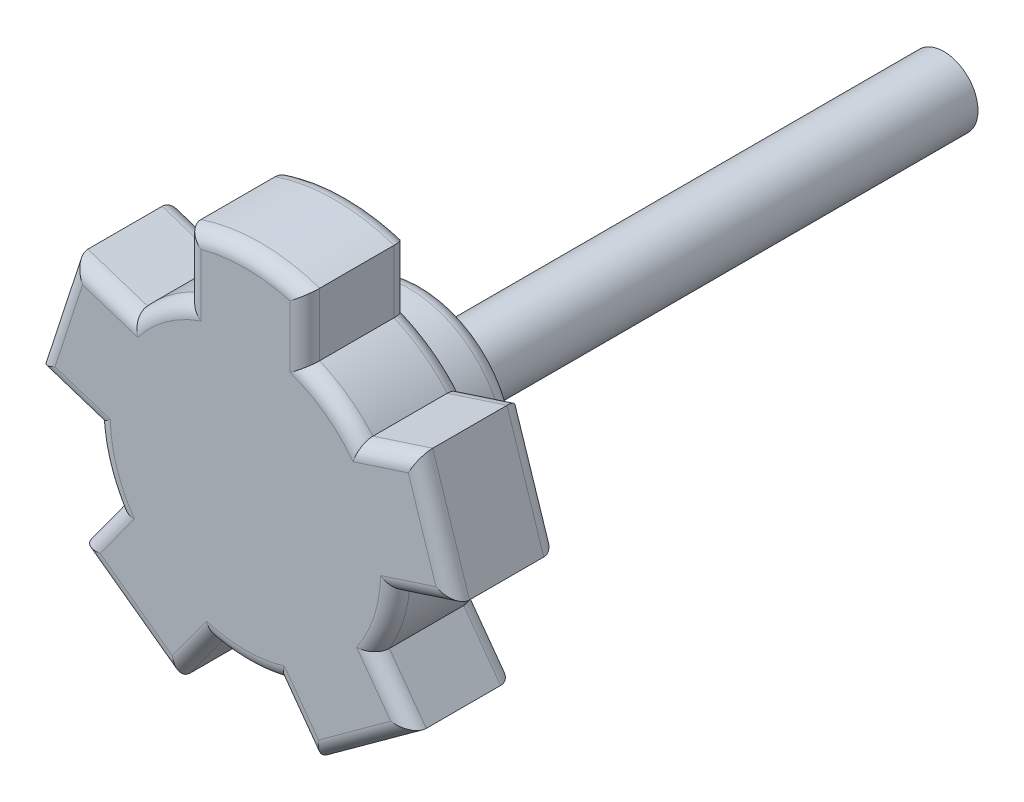
from build123d import *

# Parameters (mm, degrees)
SKETCH1_R      = 2.921
EXTRUDE1_DEPTH = 44.45
SKETCH2_R      = 8.255
EXTRUDE2_DEPTH = 6.35
SKETCH3_R      = 12.827
EXTRUDE3_DEPTH = 8.89
EXTRUDE6_DEPTH = 8.89
EXTRUDE7_DEPTH = 8.89
FILLET1_R      = 1.27


with BuildPart() as part:
    # Sketch1 → Extrude1 (new body)
    with BuildSketch(Plane.XY):
        Circle(SKETCH1_R)
    extrude(amount=EXTRUDE1_DEPTH)

    # Sketch2 → Extrude2 (add)
    with BuildSketch(Plane.XY.offset(44.45)):
        Circle(SKETCH2_R)
    extrude(amount=EXTRUDE2_DEPTH)

    # Sketch3 → Extrude3 (add)
    with BuildSketch(Plane.XY.offset(50.8)):
        Circle(SKETCH3_R)
    extrude(amount=EXTRUDE3_DEPTH)

    # Sketch4 → Extrude6 (add)
    with BuildSketch(Plane.XY.offset(59.69)):
        with BuildLine():
            Line((9.631908705, 8.47102495), (14.73605764, 10.129463471))
            Line((14.73605764, 10.129463471), (17.875670303, 0.466729266))
            Line((17.875670303, 0.466729266), (12.771521368, -1.191709256))
            ThreePointArc((12.771521368, -1.191709256), (12.199201935, 3.963760987), (9.631908705, 8.47102495))
        make_face()
        with BuildLine():
            Line((-5.08, 11.778180207), (-5.08, 17.145))
            Line((-5.08, 17.145), (5.08, 17.145))
            Line((5.08, 17.145), (5.08, 11.778180207))
            ThreePointArc((5.08, 11.778180207), (0, 12.827), (-5.08, 11.778180207))
        make_face()
        with BuildLine():
            Line((11.032846956, -6.542798869), (14.187384482, -10.884647287))
            Line((14.187384482, -10.884647287), (5.967771819, -16.85654545))
            Line((5.967771819, -16.85654545), (2.813234293, -12.514697032))
            ThreePointArc((2.813234293, -12.514697032), (7.539521431, -10.377260987), (11.032846956, -6.542798869))
        make_face()
        with BuildLine():
            Line((-2.813234293, -12.514697032), (-5.967771819, -16.85654545))
            Line((-5.967771819, -16.85654545), (-14.187384482, -10.884647287))
            Line((-14.187384482, -10.884647287), (-11.032846956, -6.542798869))
            ThreePointArc((-11.032846956, -6.542798869), (-7.539521431, -10.377260987), (-2.813234293, -12.514697032))
        make_face()
        with BuildLine():
            Line((-12.771521368, -1.191709256), (-17.875670303, 0.466729266))
            Line((-17.875670303, 0.466729266), (-14.73605764, 10.129463471))
            Line((-14.73605764, 10.129463471), (-9.631908705, 8.47102495))
            ThreePointArc((-9.631908705, 8.47102495), (-12.199201935, 3.963760987), (-12.771521368, -1.191709256))
        make_face()
    extrude(amount=-EXTRUDE6_DEPTH)

    # Sketch7 → Extrude7 (add)
    with BuildSketch(Plane.XY.offset(59.69)):
        with BuildLine():
            Line((5.08, 17.145), (-5.08, 17.145))
            ThreePointArc((-5.08, 17.145), (0, 17.989354528), (5.08, 17.145))
        make_face()
    extrude(amount=-EXTRUDE7_DEPTH)

    # Fillet1
    fillet1_edges = [part.edges().sort_by_distance(p)[0] for p in [
        (-7.539521431, 10.377260987, 59.69),
        (-7.539521431, 10.377260987, 50.8),
        (5.08, 14.461590104, 59.69),
        (-5.08, 14.461590104, 59.69),
        (5.08, 14.461590104, 50.8),
        (-5.08, 14.461590104, 50.8),
        (7.539521431, 10.377260987, 59.69),
        (7.539521431, 10.377260987, 50.8),
        (15.323595836, -0.362489995, 59.69),
        (16.305863972, 5.298096369, 59.69),
        (12.183983173, 9.300244211, 59.69),
        (15.323595836, -0.362489995, 50.8),
        (12.183983173, 9.300244211, 50.8),
        (16.305863972, 5.298096369, 50.8),
        (12.199201935, -3.963760987, 59.69),
        (12.199201935, -3.963760987, 50.8),
        (4.390503056, -14.685621241, 59.69),
        (10.077578151, -13.870596369, 59.69),
        (12.610115719, -8.713723078, 59.69),
        (4.390503056, -14.685621241, 50.8),
        (12.610115719, -8.713723078, 50.8),
        (10.077578151, -13.870596369, 50.8),
        (0, -12.827, 59.69),
        (0, -12.827, 50.8),
        (-12.610115719, -8.713723078, 59.69),
        (-10.077578151, -13.870596369, 59.69),
        (-4.390503056, -14.685621241, 59.69),
        (-12.610115719, -8.713723078, 50.8),
        (-4.390503056, -14.685621241, 50.8),
        (-10.077578151, -13.870596369, 50.8),
        (-8.255, 0, 44.45),
        (-12.199201935, -3.963760987, 59.69),
        (-8.255, 0, 50.8),
        (-12.199201935, -3.963760987, 50.8),
        (-12.183983173, 9.300244211, 59.69),
        (-16.305863972, 5.298096369, 59.69),
        (-15.323595836, -0.362489995, 59.69),
        (-12.183983173, 9.300244211, 50.8),
        (-15.323595836, -0.362489995, 50.8),
        (-16.305863972, 5.298096369, 50.8),
        (0, 17.989354528, 59.69),
        (0, 17.989354528, 50.8),
    ]]
    fillet(fillet1_edges, radius=FILLET1_R)


solid = part.part
